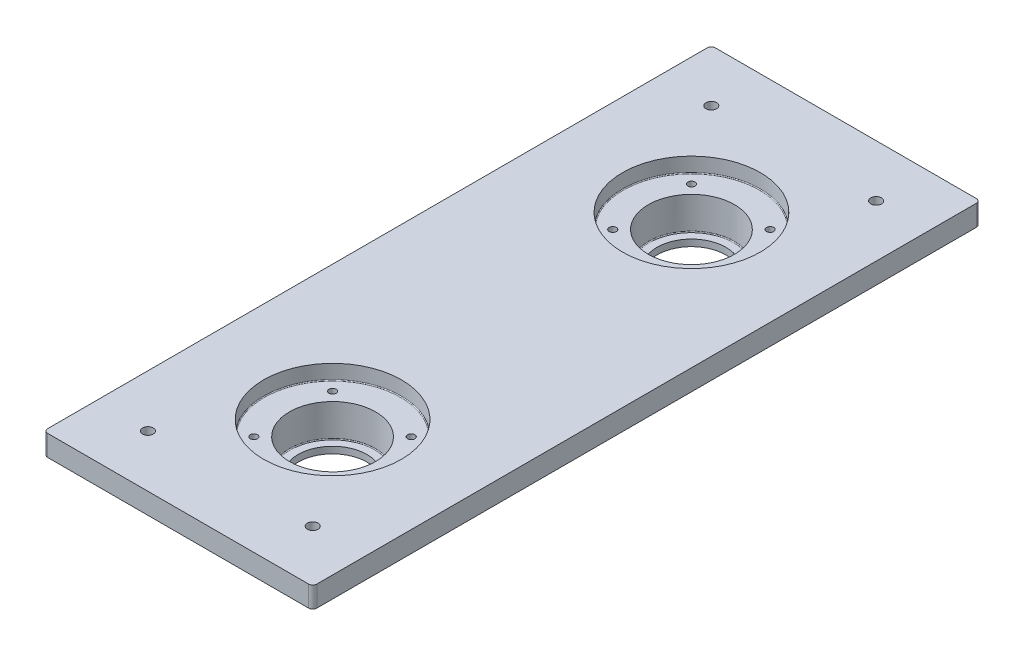
from build123d import *

# Parameters (mm, degrees)
SKETCH1_W               = 129
SKETCH1_H               = 320
EXTRUDE1_DEPTH          = 10
SKETCH2_R               = 23.81885
EXTRUDE2_DEPTH          = 25.920000024
SKETCH3_R               = 16.51
EXTRUDE3_DEPTH          = 26.920000024
SKETCH4_R               = 20.64385
EXTRUDE4_DEPTH          = 22.745
SKETCH5_R               = 33.02
EXTRUDE5_DEPTH          = 7.112
SKETCH11_R              = 35.56
SKETCH11_R_2            = 23.81885
BOSS_EXTRUDE2_DEPTH     = 8.382
F_8_32_TAPPED_HOLE1_D   = 3.4544
FILLET1_R               = 0.39624
FILLET2_R               = 2
F_1_4_20_TAPPED_HOLE1_D = 5.1054
MIRROR3_COPY_1_D        = 5.1054


with BuildPart() as part:
    # Sketch1 → Extrude1 (new body)
    with BuildSketch(Plane(origin=(0, 0, 0), x_dir=(1, 0, 0), z_dir=(0, 1, 0))):
        Rectangle(SKETCH1_W, SKETCH1_H)
    extrude(amount=EXTRUDE1_DEPTH)

    # Sketch2 → Extrude2 (add)
    with BuildSketch(Plane.XZ.offset(-10)):
        with Locations(Location((0, -86, 0), (0, 0, 90))):  # turned: the seam where the file's is
            Circle(SKETCH2_R)
    extrude2 = extrude(amount=EXTRUDE2_DEPTH)

    # Sketch3 → Extrude3 (cut, through all)
    with BuildSketch(Plane.XZ.offset(15.920000024)):
        with Locations(Location((0, -86, 0), (0, 0, 270))):  # turned: the seam where the file's is
            Circle(SKETCH3_R)
    extrude3 = extrude(amount=-EXTRUDE3_DEPTH, mode=Mode.SUBTRACT)

    # Sketch4 → Extrude4 (cut)
    with BuildSketch(Plane(origin=(0, 10, 0), x_dir=(1, 0, 0), z_dir=(0, 1, 0))):
        with Locations(Location((0, 86, 0), (0, 0, 270))):  # turned: the seam where the file's is
            Circle(SKETCH4_R)
    extrude4 = extrude(amount=-EXTRUDE4_DEPTH, mode=Mode.SUBTRACT)

    # Sketch5 → Extrude5 (cut)
    with BuildSketch(Plane(origin=(0, 10, 0), x_dir=(1, 0, 0), z_dir=(0, 1, 0))):
        with Locations(Location((0, 86, 0), (0, 0, 270))):  # turned: the seam where the file's is
            Circle(SKETCH5_R)
    extrude5 = extrude(amount=-EXTRUDE5_DEPTH, mode=Mode.SUBTRACT)

    # Sketch11 → Boss-Extrude2 (add)
    with BuildSketch(Plane.XZ.offset(-2.888)):
        with Locations(Location((0, -86, 0), (0, 0, 90))):  # turned: the seam where the file's is
            Circle(SKETCH11_R)
        with Locations(Location((0, -86, 0), (0, 0, 270))):  # turned: the seam where the file's is
            Circle(SKETCH11_R_2, mode=Mode.SUBTRACT)
    boss_extrude2 = extrude(amount=BOSS_EXTRUDE2_DEPTH)

    # #8-32 Tapped Hole1 (through all)
    with Locations(Plane(origin=(-18.858537854, 2.888, -104.858537854), x_dir=(0, 0, 1), z_dir=(0, 1, 0))):
        with Locations((0, 0), (0, 37.717075708), (37.717075708, 37.717075708), (37.717075708, 0)):
            f_8_32_tapped_hole1 = Hole(F_8_32_TAPPED_HOLE1_D / 2)

    # Mirror1: Extrude2, Extrude3, Extrude4, Extrude5, Boss-Extrude2, #8-32 Tapped Hole1 across plane
    add(extrude2.mirror(Plane.XY))
    add(extrude3.mirror(Plane.XY), mode=Mode.SUBTRACT)
    add(extrude4.mirror(Plane.XY), mode=Mode.SUBTRACT)
    add(extrude5.mirror(Plane.XY), mode=Mode.SUBTRACT)
    add(boss_extrude2.mirror(Plane.XY))
    add(f_8_32_tapped_hole1.mirror(Plane.XY), mode=Mode.SUBTRACT)

    # Fillet1
    fillet1_edges = [part.edges().sort_by_distance(p)[0] for p in [
        (0, -12.745, -106.64385),
        (0, 2.888, -119.02),
        (0, 0, -121.56),
        (0, -5.494, -109.81885),
        (0, -12.745, 106.64385),
        (0, 2.888, 119.02),
        (0, -5.494, 109.81885),
        (0, 0, 121.56),
    ]]
    fillet(fillet1_edges, radius=FILLET1_R)

    # Fillet2
    fillet2_edges = [part.edges().sort_by_distance(p)[0] for p in [
        (-64.5, 5, -160),
        (64.5, 5, -160),
        (64.5, 5, 160),
        (-64.5, 5, 160),
    ]]
    fillet(fillet2_edges, radius=FILLET2_R)

    # 1/4-20 Tapped Hole1 (through all)
    with Locations(Plane(origin=(0, 10, 0), x_dir=(-1, 0, 0), z_dir=(0, 1, 0))):
        with Locations((39.5, -135)):
            f_1_4_20_tapped_hole1 = Hole(F_1_4_20_TAPPED_HOLE1_D / 2)

    # Mirror2: 1/4-20 Tapped Hole1 across plane
    add(f_1_4_20_tapped_hole1.mirror(Plane(origin=(0, 0, 0), x_dir=(0, 0, 1), z_dir=(1, 0, 0))), mode=Mode.SUBTRACT)

    # Mirror3: 1/4-20 Tapped Hole1 across plane
    add(f_1_4_20_tapped_hole1.mirror(Plane.XY), mode=Mode.SUBTRACT)

    # Mirror3 copy 1 (through all)
    with Locations(Plane(origin=(0, 10, 0), x_dir=(1, 0, 0), z_dir=(0, 1, 0))):
        with Locations((39.5, -135)):
            Hole(MIRROR3_COPY_1_D / 2)


solid = part.part
